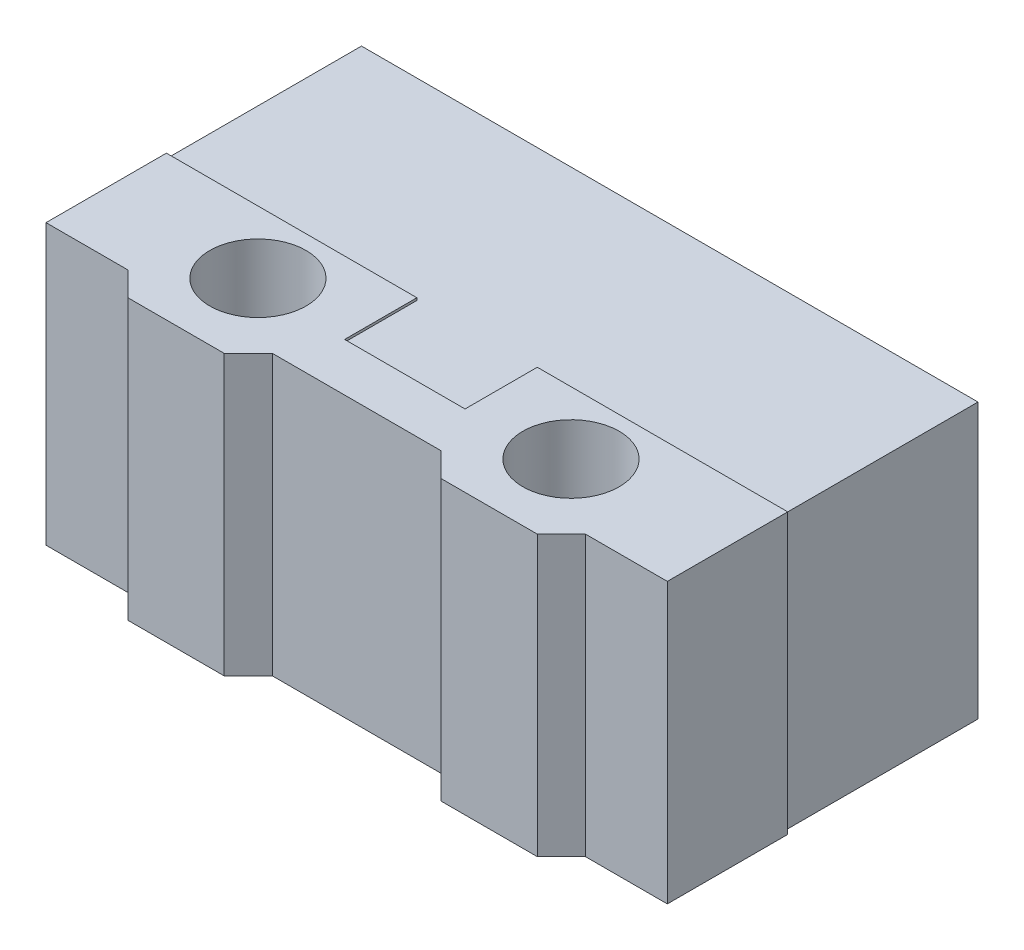
from build123d import *

# Parameters (mm, degrees)
BOSS_EXTRUDE1_DEPTH   = 2.85
BOSS_EXTRUDE2_DEPTH   = 2.9
F_2_0MM_DOWEL_HOLE1_D = 2


with BuildPart() as part:
    # Sketch1 → Boss-Extrude1 (new, symmetric)
    with BuildSketch(Plane(origin=(0, 0, 0), x_dir=(1, 0, 0), z_dir=(0, 1, 0))):
        Polygon((-6.4, 3.25), (-6.4, -0.75), (-1.25, -0.75), (-1.25, -2.25), (1.25, -2.25), (1.25, -0.75), (6.4, -0.75), (6.4, 3.25), align=None)
    extrude(amount=BOSS_EXTRUDE1_DEPTH, both=True)

    # Sketch1_3 → Boss-Extrude2 (add, symmetric)
    with BuildSketch(Plane(origin=(0, 0, 0), x_dir=(1, 0, 0), z_dir=(0, 1, 0))):
        Polygon((-1.25, -0.75), (-6.45, -0.75), (-6.45, -3.25), (-4.75, -3.25), (-4.25, -3.75), (-2.25, -3.75), (-1.75, -3.25), (1.75, -3.25), (2.25, -3.75), (4.25, -3.75), (4.75, -3.25), (6.45, -3.25), (6.45, -0.75), (1.25, -0.75), (1.25, -2.25), (-1.25, -2.25), align=None)
    extrude(amount=BOSS_EXTRUDE2_DEPTH, both=True)

    # Ø2.0mm Dowel Hole1 (through all)
    with Locations(Plane(origin=(0, -2.9, 0), x_dir=(-1, 0, 0), z_dir=(0, -1, 0))):
        with Locations((3.25, -2.05), (-3.25, -2.05)):
            Hole(F_2_0MM_DOWEL_HOLE1_D / 2)


solid = part.part
